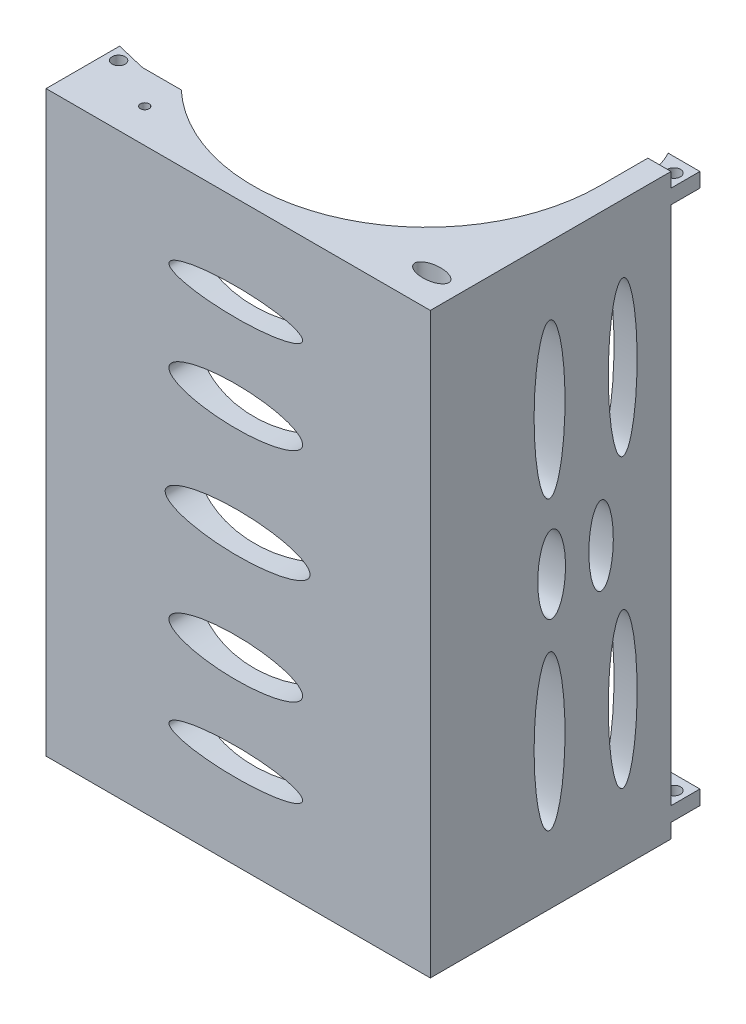
from build123d import *

# Parameters (mm, degrees)
BOSS_EXTRUDE1_DEPTH     = 200
SKETCH3_W               = 30
SKETCH3_H               = 188
CUT_EXTRUDE1_DEPTH      = 133.922594433
SKETCH8_W               = 8
SKETCH8_H               = 5
CUT_EXTRUDE2_DEPTH      = 8
SKETCH9_R               = 2.25
CUT_EXTRUDE3_DEPTH      = 20
SKETCH11_R              = 1.5
CUT_EXTRUDE5_DEPTH      = 227
CUT_EXTRUDE7_DEPTH      = 258
SKETCH16_RX             = 26.731295142
SKETCH16_RY             = 4.98984176
SKETCH16_RY_2           = 5.346259028
CUT_EXTRUDE8_DEPTH      = 20
SKETCH17_W              = 132.922594433
SKETCH17_H              = 30
CUT_EXTRUDE9_DEPTH      = 6.0000001
CUT_EXTRUDE9_DEPTH_BACK = 196.0000001
SKETCH18_R              = 2.25
BOSS_EXTRUDE2_DEPTH     = 5
SKETCH20_R              = 1.5
CUT_EXTRUDE10_DEPTH     = 15
SKETCH21_RX             = 23.130438637
SKETCH21_RY             = 4.769162606
SKETCH21_RY_2           = 6.676827648
CUT_EXTRUDE11_DEPTH     = 50
SKETCH23_RX             = 25.050101066
SKETCH23_RY             = 6.906071423
CUT_EXTRUDE12_DEPTH     = 40
SKETCH24_RX             = 13.620339157
SKETCH24_RY             = 4.233977798
SKETCH24_RX_2           = 13.399068338
SKETCH24_RY_2           = 4.798334401
CUT_EXTRUDE13_DEPTH     = 40
SKETCH25_RX             = 46.189311341
SKETCH25_RY             = 4.74039437
CUT_EXTRUDE14_DEPTH     = 20
SKETCH26_RX             = 5.884651804
SKETCH26_RY             = 3.051300935
CUT_EXTRUDE15_DEPTH     = 201.0000001


with BuildPart() as part:
    # Sketch2 → Boss-Extrude1 (new body)
    with BuildSketch(Plane(origin=(0, 0, 0), x_dir=(1, 0, 0), z_dir=(0, 1, 0))):
        with BuildLine():
            Line((-91.240837696, -7.845549738), (36.759162304, -7.845549738))
            Line((36.759162304, -7.845549738), (41.681756737, -7.845549738))
            Line((41.681756737, -7.845549738), (41.681756737, 105.412473794))
            Line((41.681756737, 105.412473794), (33.681756737, 105.412473794))
            Line((33.681756737, 105.412473794), (33.681756737, 88.806933971))
            ThreePointArc((33.681756737, 88.806933971), (-2.531485377, 33.723450518), (-67.457914906, 45.131684491))
            Line((-67.457914906, 45.131684491), (-80.810408296, 45.131684491))
            ThreePointArc((-80.810408296, 45.131684491), (-86.038260088, 46.340819049), (-91.240837696, 47.654450262))
            Line((-91.240837696, 47.654450262), (-91.240837696, -7.845549738))
        make_face()
    extrude(amount=BOSS_EXTRUDE1_DEPTH)

    # Sketch3 → Cut-Extrude1 (cut, through all)
    with BuildSketch(Plane.ZY.offset(91.240837696)):
        with Locations((-7.154450262, 100)):
            Rectangle(SKETCH3_W, SKETCH3_H)
    extrude(amount=-CUT_EXTRUDE1_DEPTH, mode=Mode.SUBTRACT)

    # Sketch8 → Cut-Extrude2 (cut)
    with BuildSketch(Plane.ZY.offset(91.240837696)):
        with Locations((-43.654450262, 192.5)):
            Rectangle(SKETCH8_W, SKETCH8_H)
    cut_extrude2 = extrude(amount=-CUT_EXTRUDE2_DEPTH, mode=Mode.SUBTRACT)

    # Mirror2: Cut-Extrude2 across plane
    add(cut_extrude2.mirror(Plane.ZX.offset(100)), mode=Mode.SUBTRACT)

    # Sketch9 → Cut-Extrude3 (cut)
    with BuildSketch(Plane(origin=(0, 200, 0), x_dir=(1, 0, 0), z_dir=(0, 1, 0))):
        with Locations((-87.125618482, 43.130480477)):
            Circle(SKETCH9_R)
    cut_extrude3 = extrude(amount=-CUT_EXTRUDE3_DEPTH, mode=Mode.SUBTRACT)

    # Mirror3: Cut-Extrude3 across plane
    add(cut_extrude3.mirror(Plane.ZX.offset(100)), mode=Mode.SUBTRACT)

    # Sketch11 → Cut-Extrude5 (cut)
    with BuildSketch(Plane(origin=(0, 200, 0), x_dir=(1, 0, 0), z_dir=(0, 1, 0))):
        with Locations((-68.865823893, 16.291817364)):
            Circle(SKETCH11_R)
    extrude(amount=-CUT_EXTRUDE5_DEPTH, mode=Mode.SUBTRACT)

    # Sketch13 → Cut-Extrude7 (cut)
    with BuildSketch(Plane.XZ):
        Polygon((-74.8616816, 7.845549738), (36.602444116, 7.845549738), (36.602444116, -6.112801574), (36.602444116, -22.154450262), (-56.44082025, -22.154450262), (-56.44082025, -6.112801574), (-74.8616816, -6.112801574), align=None)
    extrude(amount=-CUT_EXTRUDE7_DEPTH, mode=Mode.SUBTRACT)

    # Sketch16 → Cut-Extrude8 (cut)
    with BuildSketch(Plane(origin=(41.681756737, 0, 0), x_dir=(0, 0, -1), z_dir=(1, 0, 0))):
        with Locations(Location((88.702196106, 149.720208964), (0, 0, 90))):
            Ellipse(SKETCH16_RX, SKETCH16_RY)
        with Locations(Location((63.396570039, 149.720208964), (0, 0, 90))):
            Ellipse(SKETCH16_RX, SKETCH16_RY_2)
    cut_extrude8 = extrude(amount=-CUT_EXTRUDE8_DEPTH, mode=Mode.SUBTRACT)

    # Mirror4: Cut-Extrude8 across plane
    add(cut_extrude8.mirror(Plane.ZX.offset(100)), mode=Mode.SUBTRACT)

    # Sketch17 → Cut-Extrude9 (cut, two sides)
    with BuildSketch(Plane(origin=(0, 195, 0), x_dir=(1, 0, 0), z_dir=(0, 1, 0))) as cut_extrude9_sk:
        with Locations((-24.779540479, 7.154450262)):
            Rectangle(SKETCH17_W, SKETCH17_H)
    extrude(amount=CUT_EXTRUDE9_DEPTH, mode=Mode.SUBTRACT)
    extrude(cut_extrude9_sk.sketch, amount=-CUT_EXTRUDE9_DEPTH_BACK, mode=Mode.SUBTRACT)

    # Sketch18 → Boss-Extrude2 (add)
    with BuildSketch(Plane(origin=(0, 195, 0), x_dir=(1, 0, 0), z_dir=(0, 1, 0))):
        with BuildLine():
            Line((30.717635907, 115.412473794), (33.681756737, 115.412473794))
            Line((33.681756737, 115.412473794), (41.681756737, 115.412473794))
            Line((41.681756737, 115.412473794), (41.681756737, 105.412473794))
            Line((41.681756737, 105.412473794), (33.681756737, 105.412473794))
            ThreePointArc((33.681756737, 105.412473794), (32.704307675, 110.562046696), (30.717635907, 115.412473794))
        make_face()
        with Locations((37.681756737, 110.446980465)):
            Circle(SKETCH18_R, mode=Mode.SUBTRACT)
    boss_extrude2 = extrude(amount=-BOSS_EXTRUDE2_DEPTH)

    # Mirror5: Boss-Extrude2 across plane
    add(boss_extrude2.mirror(Plane.ZX.offset(100)))

    # Sketch20 → Cut-Extrude10 (cut)
    with BuildSketch(Plane(origin=(0, 200, 0), x_dir=(1, 0, 0), z_dir=(0, 1, 0))):
        with Locations((-68.865823893, 33.911680749)):
            Circle(SKETCH20_R)
    cut_extrude10 = extrude(amount=-CUT_EXTRUDE10_DEPTH, mode=Mode.SUBTRACT)

    # Mirror6: Cut-Extrude10 across plane
    add(cut_extrude10.mirror(Plane.ZX.offset(100)), mode=Mode.SUBTRACT)

    # Sketch21 → Cut-Extrude11 (cut)
    with BuildSketch(Plane.XY.offset(-22.154450262)):
        with Locations(Location((-25.628029882, 168.886718185), (0, 0, 180))):
            Ellipse(SKETCH21_RX, SKETCH21_RY)
        with Locations(Location((-25.628029882, 137.648703119), (0, 0, 180))):
            Ellipse(SKETCH21_RX, SKETCH21_RY_2)
    cut_extrude11 = extrude(amount=-CUT_EXTRUDE11_DEPTH, mode=Mode.SUBTRACT)

    # Mirror7: Cut-Extrude11 across plane
    add(cut_extrude11.mirror(Plane.ZX.offset(100)), mode=Mode.SUBTRACT)

    # Sketch23 → Cut-Extrude12 (cut)
    with BuildSketch(Plane.XY.offset(-22.154450262)):
        with Locations(Location((-24.989343218, 100), (0, 0, 180))):
            Ellipse(SKETCH23_RX, SKETCH23_RY)
    extrude(amount=-CUT_EXTRUDE12_DEPTH, mode=Mode.SUBTRACT)

    # Sketch24 → Cut-Extrude13 (cut)
    with BuildSketch(Plane(origin=(41.681756737, 0, 0), x_dir=(0, 0, -1), z_dir=(1, 0, 0))):
        with Locations(Location((81.218448087, 100), (0, 0, 90))):
            Ellipse(SKETCH24_RX, SKETCH24_RY)
        with Locations(Location((64.112673949, 100), (0, 0, 90))):
            Ellipse(SKETCH24_RX_2, SKETCH24_RY_2)
    extrude(amount=-CUT_EXTRUDE13_DEPTH, mode=Mode.SUBTRACT)

    # Sketch25 → Cut-Extrude14 (cut)
    with BuildSketch(Plane.ZY.offset(91.240837696)):
        with Locations(Location((-35.575386951, 100), (0, 0, 90))):
            Ellipse(SKETCH25_RX, SKETCH25_RY)
    extrude(amount=-CUT_EXTRUDE14_DEPTH, mode=Mode.SUBTRACT)

    # Sketch26 → Cut-Extrude15 (cut, through all)
    with BuildSketch(Plane(origin=(0, 200, 0), x_dir=(1, 0, 0), z_dir=(0, 1, 0))):
        with Locations(Location((30.671294914, 33.657160335), (0, 0, 180))):
            Ellipse(SKETCH26_RX, SKETCH26_RY)
    extrude(amount=-CUT_EXTRUDE15_DEPTH, mode=Mode.SUBTRACT)


solid = part.part
